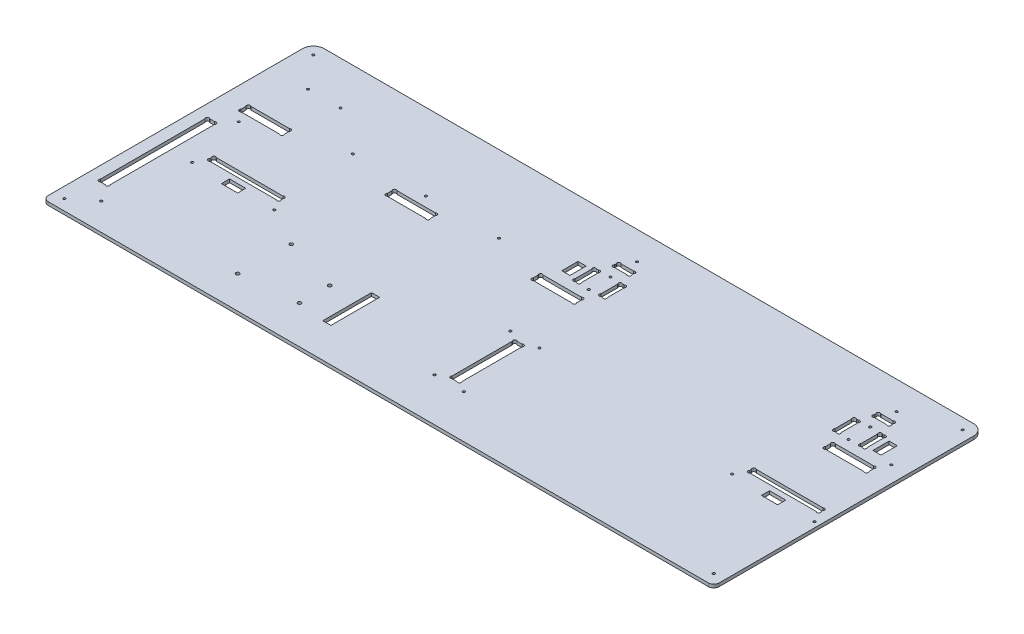
from build123d import *

# Parameters (mm, degrees)
ESQUISSE1_R             = 1.1
EXTRUSION1_DEPTH        = 3
ESQUISSE3_R             = 1.1
ENL_V_MAT_EXTRU_2_DEPTH = 4
CONG_1_R                = 5
ESQUISSE4_R             = 1.1
ENL_V_MAT_EXTRU_3_DEPTH = 4
ESQUISSE5_R             = 1.59
ENL_V_MAT_EXTRU_4_DEPTH = 4
ESQUISSE6_W             = 15
ESQUISSE6_H             = 7.5
ESQUISSE6_W_2           = 7.5
ESQUISSE6_H_2           = 15
ESQUISSE6_H_3           = 45
ENL_V_MAT_EXTRU_5_DEPTH = 4
ESQUISSE7_R             = 1.1
ENL_V_MAT_EXTRU_6_DEPTH = 4


with BuildPart() as part:
    # Esquisse1 → Extrusion1 (new body)
    with BuildSketch(Plane(origin=(0, 0, 0), x_dir=(1, 0, 0), z_dir=(0, 1, 0))):
        with BuildLine():
            Line((10, 250), (610, 250))
            ThreePointArc((610, 250), (617.071067812, 247.071067812), (620, 240))
            Line((620, 240), (620, 0))
            Line((620, 0), (0, 0))
            Line((0, 0), (0, 240))
            ThreePointArc((0, 240), (2.928932188, 247.071067812), (10, 250))
        make_face()
        with Locations(Location((539, 98, 0), (0, 0, 270))):  # turned: the seam where the file's is
            Circle(ESQUISSE1_R, mode=Mode.SUBTRACT)
        with Locations(Location((615, 98, 0), (0, 0, 270))):  # turned: the seam where the file's is
            Circle(ESQUISSE1_R, mode=Mode.SUBTRACT)
        with BuildLine():
            Line((317, 211.2627417), (317, 212.7372583))
            ThreePointArc((317, 212.7372583), (317, 215), (319.2627417, 215))
            Line((319.2627417, 215), (330.7372583, 215))
            ThreePointArc((330.7372583, 215), (333, 215), (333, 212.7372583))
            Line((333, 212.7372583), (333, 211.2627417))
            ThreePointArc((333, 211.2627417), (333, 209), (330.737258301, 209))
            Line((330.737258301, 209), (319.262741699, 209))
            ThreePointArc((319.262741699, 209), (316.999999999, 209.000000001), (317, 211.2627417))
        make_face(mode=Mode.SUBTRACT)
        with BuildLine():
            Line((312.262741699, 179.5), (313.737258301, 179.5))
            ThreePointArc((313.737258301, 179.5), (316.000000001, 179.500000001), (316, 181.762741701))
            Line((316, 181.762741701), (316, 197.237258299))
            ThreePointArc((316, 197.237258299), (316.000000001, 199.499999999), (313.737258301, 199.5))
            Line((313.737258301, 199.5), (312.262741699, 199.5))
            ThreePointArc((312.262741699, 199.5), (309.999999999, 199.499999999), (310, 197.237258299))
            Line((310, 197.237258299), (310, 181.762741701))
            ThreePointArc((310, 181.762741701), (309.999999999, 179.500000001), (312.262741699, 179.5))
        make_face(mode=Mode.SUBTRACT)
        with BuildLine():
            Line((334, 181.762741701), (334, 197.2372583))
            ThreePointArc((334, 197.2372583), (334, 199.5), (336.2627417, 199.5))
            Line((336.2627417, 199.5), (337.7372583, 199.5))
            ThreePointArc((337.7372583, 199.5), (340, 199.5), (340, 197.2372583))
            Line((340, 197.2372583), (340, 181.762741701))
            ThreePointArc((340, 181.762741701), (340.000000001, 179.500000001), (337.737258301, 179.5))
            Line((337.737258301, 179.5), (336.262741699, 179.5))
            ThreePointArc((336.262741699, 179.5), (333.999999999, 179.500000001), (334, 181.762741701))
        make_face(mode=Mode.SUBTRACT)
        with BuildLine():
            Line((552.2627417, 179.5), (553.7372583, 179.5))
            ThreePointArc((553.7372583, 179.5), (556, 179.5), (556, 181.7627417))
            Line((556, 181.7627417), (556, 197.2372583))
            ThreePointArc((556, 197.2372583), (556, 199.5), (553.7372583, 199.5))
            Line((553.7372583, 199.5), (552.2627417, 199.5))
            ThreePointArc((552.2627417, 199.5), (550, 199.5), (550, 197.2372583))
            Line((550, 197.2372583), (550, 181.7627417))
            ThreePointArc((550, 181.7627417), (550, 179.5), (552.2627417, 179.5))
        make_face(mode=Mode.SUBTRACT)
        with BuildLine():
            Line((574, 181.7627417), (574, 197.2372583))
            ThreePointArc((574, 197.2372583), (574, 199.5), (576.2627417, 199.5))
            Line((576.2627417, 199.5), (577.7372583, 199.5))
            ThreePointArc((577.7372583, 199.5), (580, 199.5), (580, 197.2372583))
            Line((580, 197.2372583), (580, 181.7627417))
            ThreePointArc((580, 181.7627417), (580, 179.5), (577.7372583, 179.5))
            Line((577.7372583, 179.5), (576.2627417, 179.5))
            ThreePointArc((576.2627417, 179.5), (574, 179.5), (574, 181.7627417))
        make_face(mode=Mode.SUBTRACT)
        with BuildLine():
            Line((559.2627417, 209), (570.7372583, 209))
            ThreePointArc((570.7372583, 209), (573, 209), (573, 211.2627417))
            Line((573, 211.2627417), (573, 212.7372583))
            ThreePointArc((573, 212.7372583), (573, 215), (570.7372583, 215))
            Line((570.7372583, 215), (559.2627417, 215))
            ThreePointArc((559.2627417, 215), (557, 215), (557, 212.7372583))
            Line((557, 212.7372583), (557, 211.2627417))
            ThreePointArc((557, 211.2627417), (557, 209), (559.2627417, 209))
        make_face(mode=Mode.SUBTRACT)
        with BuildLine():
            Line((560, 167.7372583), (560, 163.2627417))
            ThreePointArc((560, 163.2627417), (560, 161), (562.2627417, 161))
            Line((562.2627417, 161), (597.7372583, 161))
            ThreePointArc((597.7372583, 161), (600, 161), (600, 163.2627417))
            Line((600, 163.2627417), (600, 167.7372583))
            ThreePointArc((600, 167.7372583), (600, 170), (597.7372583, 170))
            Line((597.7372583, 170), (562.2627417, 170))
            ThreePointArc((562.2627417, 170), (560, 170), (560, 167.7372583))
        make_face(mode=Mode.SUBTRACT)
        with BuildLine():
            Line((292.2627417, 161), (327.7372583, 161))
            ThreePointArc((327.7372583, 161), (330, 161), (330, 163.2627417))
            Line((330, 163.2627417), (330, 167.7372583))
            ThreePointArc((330, 167.7372583), (330, 170), (327.7372583, 170))
            Line((327.7372583, 170), (292.2627417, 170))
            ThreePointArc((292.2627417, 170), (290, 170), (290, 167.7372583))
            Line((290, 167.7372583), (290, 163.2627417))
            ThreePointArc((290, 163.2627417), (290, 161), (292.2627417, 161))
        make_face(mode=Mode.SUBTRACT)
        with BuildLine():
            Line((20, 167.7372583), (20, 163.2627417))
            ThreePointArc((20, 163.2627417), (20, 161), (22.2627417, 161))
            Line((22.2627417, 161), (57.7372583, 161))
            ThreePointArc((57.7372583, 161), (60, 161), (60, 163.2627417))
            Line((60, 163.2627417), (60, 167.7372583))
            ThreePointArc((60, 167.7372583), (60, 170), (57.7372583, 170))
            Line((57.7372583, 170), (22.2627417, 170))
            ThreePointArc((22.2627417, 170), (20, 170), (20, 167.7372583))
        make_face(mode=Mode.SUBTRACT)
        with BuildLine():
            Line((155, 167.7372583), (155, 163.2627417))
            ThreePointArc((155, 163.2627417), (155, 161), (157.2627417, 161))
            Line((157.2627417, 161), (192.7372583, 161))
            ThreePointArc((192.7372583, 161), (195, 161), (195, 163.2627417))
            Line((195, 163.2627417), (195, 167.7372583))
            ThreePointArc((195, 167.7372583), (195, 170), (192.7372583, 170))
            Line((192.7372583, 170), (157.2627417, 170))
            ThreePointArc((157.2627417, 170), (155, 170), (155, 167.7372583))
        make_face(mode=Mode.SUBTRACT)
        with BuildLine():
            Line((13.2627417, 40), (17.7372583, 40))
            ThreePointArc((17.7372583, 40), (20, 40), (20, 42.2627417))
            Line((20, 42.2627417), (20, 138.7372583))
            ThreePointArc((20, 138.7372583), (20, 141), (17.7372583, 141))
            Line((17.7372583, 141), (13.2627417, 141))
            ThreePointArc((13.2627417, 141), (11, 141), (11, 138.7372583))
            Line((11, 138.7372583), (11, 42.2627417))
            ThreePointArc((11, 42.2627417), (11, 40), (13.2627417, 40))
        make_face(mode=Mode.SUBTRACT)
        with BuildLine():
            Line((337.7372583, 45), (333.2627417, 45))
            ThreePointArc((333.2627417, 45), (331, 45), (331, 47.2627417))
            Line((331, 47.2627417), (331, 102.7372583))
            ThreePointArc((331, 102.7372583), (331, 105), (333.2627417, 105))
            Line((333.2627417, 105), (337.7372583, 105))
            ThreePointArc((337.7372583, 105), (340, 105), (340, 102.7372583))
            Line((340, 102.7372583), (340, 47.2627417))
            ThreePointArc((340, 47.2627417), (340, 45), (337.7372583, 45))
        make_face(mode=Mode.SUBTRACT)
        with BuildLine():
            Line((610, 109.2627417), (610, 110.7372583))
            ThreePointArc((610, 110.7372583), (610, 113), (607.7372583, 113))
            Line((607.7372583, 113), (546.2627417, 113))
            ThreePointArc((546.2627417, 113), (544, 113), (544, 110.7372583))
            Line((544, 110.7372583), (544, 109.2627417))
            ThreePointArc((544, 109.2627417), (544, 107), (546.2627417, 107))
            Line((546.2627417, 107), (607.7372583, 107))
            ThreePointArc((607.7372583, 107), (610, 107), (610, 109.2627417))
        make_face(mode=Mode.SUBTRACT)
        with BuildLine():
            Line((108.7372583, 113), (47.2627417, 113))
            ThreePointArc((47.2627417, 113), (45, 113), (45, 110.7372583))
            Line((45, 110.7372583), (45, 109.2627417))
            ThreePointArc((45, 109.2627417), (45, 107), (47.2627417, 107))
            Line((47.2627417, 107), (108.7372583, 107))
            ThreePointArc((108.7372583, 107), (111, 107), (111, 109.2627417))
            Line((111, 109.2627417), (111, 110.7372583))
            ThreePointArc((111, 110.7372583), (111, 113), (108.7372583, 113))
        make_face(mode=Mode.SUBTRACT)
    extrude(amount=EXTRUSION1_DEPTH)

    # Esquisse3 → Enlèv. mat.-Extru.2 (cut, through all)
    with BuildSketch(Plane(origin=(0, 3, 0), x_dir=(1, 0, 0), z_dir=(0, 1, 0))):
        with Locations(Location((565, 179.5, 0), (0, 0, 270))):  # turned: the seam where the file's is
            Circle(ESQUISSE3_R)
        with Locations(Location((565, 199.5, 0), (0, 0, 270))):  # turned: the seam where the file's is
            Circle(ESQUISSE3_R)
        with Locations(Location((325, 179.5, 0), (0, 0, 270))):  # turned: the seam where the file's is
            Circle(ESQUISSE3_R)
        with Locations(Location((325, 199.5, 0), (0, 0, 270))):  # turned: the seam where the file's is
            Circle(ESQUISSE3_R)
    extrude(amount=-ENL_V_MAT_EXTRU_2_DEPTH, mode=Mode.SUBTRACT)

    # Congé1
    cong_1_edges = [part.edges().sort_by_distance(p)[0] for p in [
        (620, 1.5, 0),
        (0, 1.5, 0),
    ]]
    fillet(cong_1_edges, radius=CONG_1_R)

    # Esquisse4 → Enlèv. mat.-Extru.3 (cut, through all)
    with BuildSketch(Plane.XZ):
        with Locations(Location((10, -10, 0), (0, 0, 270))):  # turned: the seam where the file's is
            Circle(ESQUISSE4_R)
        with Locations(Location((610, -10, 0), (0, 0, 270))):  # turned: the seam where the file's is
            Circle(ESQUISSE4_R)
        with Locations(Location((610, -240, 0), (0, 0, 270))):  # turned: the seam where the file's is
            Circle(ESQUISSE4_R)
        with Locations(Location((10, -240, 0), (0, 0, 270))):  # turned: the seam where the file's is
            Circle(ESQUISSE4_R)
    extrude(amount=-ENL_V_MAT_EXTRU_3_DEPTH, mode=Mode.SUBTRACT)

    # Esquisse5 → Enlèv. mat.-Extru.4 (cut, through all)
    with BuildSketch(Plane(origin=(0, 3, 0), x_dir=(1, 0, 0), z_dir=(0, 1, 0))):
        with Locations(Location((151.27, 78.26, 0), (0, 0, 270))):  # turned: the seam where the file's is
            Circle(ESQUISSE5_R)
        with Locations(Location((150, 30, 0), (0, 0, 270))):  # turned: the seam where the file's is
            Circle(ESQUISSE5_R)
        with Locations(Location((202.07, 63.02, 0), (0, 0, 270))):  # turned: the seam where the file's is
            Circle(ESQUISSE5_R)
        with Locations(Location((202.07, 35.08, 0), (0, 0, 270))):  # turned: the seam where the file's is
            Circle(ESQUISSE5_R)
    extrude(amount=-ENL_V_MAT_EXTRU_4_DEPTH, mode=Mode.SUBTRACT)

    # Esquisse6 → Enlèv. mat.-Extru.5 (cut, through all)
    with BuildSketch(Plane(origin=(0, 3, 0), x_dir=(1, 0, 0), z_dir=(0, 1, 0))):
        with Locations((577, 98.25)):
            Rectangle(ESQUISSE6_W, ESQUISSE6_H)
        with Locations((588.75, 189.5)):
            Rectangle(ESQUISSE6_W_2, ESQUISSE6_H_2)
        with Locations((301.25, 189.5)):
            Rectangle(ESQUISSE6_W_2, ESQUISSE6_H_2)
        with Locations((230.82, 54.13)):
            Rectangle(ESQUISSE6_W_2, ESQUISSE6_H_3)
        with Locations((78, 98.25)):
            Rectangle(ESQUISSE6_W, ESQUISSE6_H)
    extrude(amount=-ENL_V_MAT_EXTRU_5_DEPTH, mode=Mode.SUBTRACT)

    # Esquisse7 → Enlèv. mat.-Extru.6 (cut, through all)
    with BuildSketch(Plane(origin=(0, 3, 0), x_dir=(1, 0, 0), z_dir=(0, 1, 0))):
        with Locations(Location((349, 110, 0), (0, 0, 270))):  # turned: the seam where the file's is
            Circle(ESQUISSE7_R)
        with Locations(Location((349, 40, 0), (0, 0, 270))):  # turned: the seam where the file's is
            Circle(ESQUISSE7_R)
        with Locations(Location((322, 110, 0), (0, 0, 270))):  # turned: the seam where the file's is
            Circle(ESQUISSE7_R)
        with Locations(Location((322, 40, 0), (0, 0, 270))):  # turned: the seam where the file's is
            Circle(ESQUISSE7_R)
        with Locations(Location((605, 179, 0), (0, 0, 270))):  # turned: the seam where the file's is
            Circle(ESQUISSE7_R)
        with Locations(Location((565, 224, 0), (0, 0, 270))):  # turned: the seam where the file's is
            Circle(ESQUISSE7_R)
        with Locations(Location((325, 224, 0), (0, 0, 270))):  # turned: the seam where the file's is
            Circle(ESQUISSE7_R)
        with Locations(Location((175, 179, 0), (0, 0, 270))):  # turned: the seam where the file's is
            Circle(ESQUISSE7_R)
        with Locations(Location((242.5, 179, 0), (0, 0, 270))):  # turned: the seam where the file's is
            Circle(ESQUISSE7_R)
        with Locations(Location((107.5, 179, 0), (0, 0, 270))):  # turned: the seam where the file's is
            Circle(ESQUISSE7_R)
        with Locations(Location((116, 98, 0), (0, 0, 270))):  # turned: the seam where the file's is
            Circle(ESQUISSE7_R)
        with Locations(Location((40, 98, 0), (0, 0, 270))):  # turned: the seam where the file's is
            Circle(ESQUISSE7_R)
        with Locations(Location((29, 152, 0), (0, 0, 270))):  # turned: the seam where the file's is
            Circle(ESQUISSE7_R)
        with Locations(Location((29, 25, 0), (0, 0, 270))):  # turned: the seam where the file's is
            Circle(ESQUISSE7_R)
        with Locations(Location((35, 210, 0), (0, 0, 270))):  # turned: the seam where the file's is
            Circle(ESQUISSE7_R)
        with Locations(Location((65, 210, 0), (0, 0, 270))):  # turned: the seam where the file's is
            Circle(ESQUISSE7_R)
    extrude(amount=-ENL_V_MAT_EXTRU_6_DEPTH, mode=Mode.SUBTRACT)


solid = part.part
